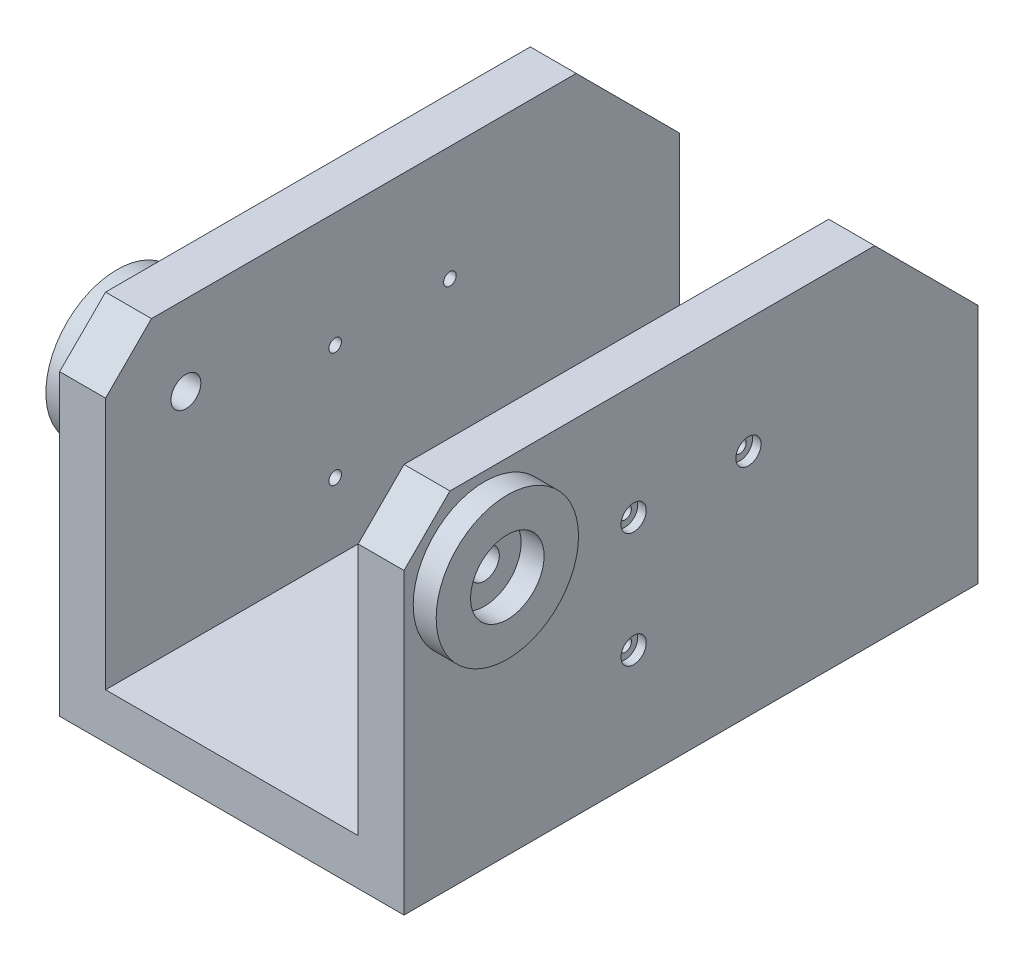
from build123d import *

# Parameters (mm, degrees)
SALIENTE_EXTRUIR1_DEPTH                              = 125
CROQUIS2_R                                           = 31
CROQUIS2_R_2                                         = 16
SALIENTE_EXTRUIR2_DEPTH                              = 10
CROQUIS4_R                                           = 6.5
CORTAR_EXTRUIR2_DEPTH                                = 161
CHAFL_N2_SIZE                                        = 20
CHAFL_N3_SIZE                                        = 45
REFRENTADO_PARA_TORNILLO_CON_CABEZA_TRON_D           = 5.5
REFRENTADO_PARA_TORNILLO_CON_CABEZA_TRON_CBORE_D     = 11
REFRENTADO_PARA_TORNILLO_CON_CABEZA_TRON_CBORE_DEPTH = 3.7


with BuildPart() as part:
    # Croquis1 → Saliente-Extruir1 (new body, symmetric)
    with BuildSketch(Plane.XY):
        Polygon((-55, 130), (-55, 0), (55, 0), (55, 130), (75, 130), (75, -20), (-75, -20), (-75, 130), align=None)
    extrude(amount=SALIENTE_EXTRUIR1_DEPTH, both=True)

    # Croquis2 → Saliente-Extruir2 (add)
    with BuildSketch(Plane(origin=(75, 0, 0), x_dir=(0, 0, -1), z_dir=(1, 0, 0))):
        with Locations(Location((-90, 95, 0), (0, 0, 180))):  # turned: the seam where the file's is
            Circle(CROQUIS2_R)
        with Locations((-90, 95)):
            Circle(CROQUIS2_R_2, mode=Mode.SUBTRACT)
    saliente_extruir2 = extrude(amount=SALIENTE_EXTRUIR2_DEPTH)

    # Simetría1: Saliente-Extruir2 across plane
    add(saliente_extruir2.mirror(Plane(origin=(0, 0, 0), x_dir=(0, 0, 1), z_dir=(1, 0, 0))))

    # Croquis4 → Cortar-Extruir2 (cut, through all)
    with BuildSketch(Plane(origin=(75, 0, 0), x_dir=(0, 0, -1), z_dir=(1, 0, 0))):
        with Locations(Location((-90, 95, 0), (0, 0, 90))):  # turned: the seam where the file's is
            Circle(CROQUIS4_R)
    extrude(amount=-CORTAR_EXTRUIR2_DEPTH, mode=Mode.SUBTRACT)

    # Chaflán2
    chafl_n2_edges = [part.edges().sort_by_distance(p)[0] for p in [
        (65, 130, 125),
        (-65, 130, 125),
    ]]
    chamfer(chafl_n2_edges, length=CHAFL_N2_SIZE)

    # Chaflán3
    chafl_n3_edges = [part.edges().sort_by_distance(p)[0] for p in [
        (-65, 130, -125),
        (65, 130, -125),
    ]]
    chamfer(chafl_n3_edges, length=CHAFL_N3_SIZE)

    # Refrentado para tornillo con cabeza troncocónica de M51 (through all)
    with Locations(Plane(origin=(75, 80, 25), x_dir=(0, 0, 1), z_dir=(1, 0, 0))):
        with Locations((0, 0), (-50, 0), (0, 50)):
            CounterBoreHole(REFRENTADO_PARA_TORNILLO_CON_CABEZA_TRON_D / 2, REFRENTADO_PARA_TORNILLO_CON_CABEZA_TRON_CBORE_D / 2, REFRENTADO_PARA_TORNILLO_CON_CABEZA_TRON_CBORE_DEPTH)


solid = part.part
